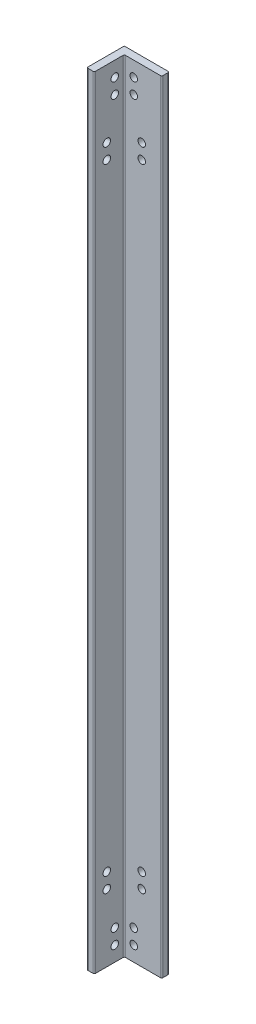
from build123d import *

# Parameters (mm, degrees)
SKETCH1_W           = 15
SKETCH1_H           = 313
SKETCH1_R           = 1.5
BOSS_EXTRUDE2_DEPTH = 3
SKETCH1_4_W         = 3
SKETCH1_4_H         = 313
BOSS_EXTRUDE3_DEPTH = 15
CUT_EXTRUDE1_REACH  = 296.576
SKETCH2_R           = 1.5
FILLET1_R           = 0.5


with BuildPart() as part:
    # Sketch1 → Boss-Extrude2 (new body)
    with BuildSketch(Plane.XY):
        with Locations((7.842857143, -137.142857143)):
            Rectangle(SKETCH1_W, SKETCH1_H)
        with Locations((4.142857143, -287.642857143)):
            Circle(SKETCH1_R, mode=Mode.SUBTRACT)
        with Locations((4.142857143, -281.642857143)):
            Circle(SKETCH1_R, mode=Mode.SUBTRACT)
        with Locations((7.342857143, -266.642857143)):
            Circle(SKETCH1_R, mode=Mode.SUBTRACT)
        with Locations((7.342857143, -260.642857143)):
            Circle(SKETCH1_R, mode=Mode.SUBTRACT)
        with Locations((4.142857143, 7.357142857)):
            Circle(SKETCH1_R, mode=Mode.SUBTRACT)
        with Locations((4.142857143, 13.357142857)):
            Circle(SKETCH1_R, mode=Mode.SUBTRACT)
        with Locations((7.342857143, -13.642857143)):
            Circle(SKETCH1_R, mode=Mode.SUBTRACT)
        with Locations((7.342857143, -7.642857143)):
            Circle(SKETCH1_R, mode=Mode.SUBTRACT)
    extrude(amount=BOSS_EXTRUDE2_DEPTH)

    # Sketch1_4 → Boss-Extrude3 (add)
    with BuildSketch(Plane.XY):
        with Locations((-1.157142857, -137.142857143)):
            Rectangle(SKETCH1_4_W, SKETCH1_4_H)
    extrude(amount=BOSS_EXTRUDE3_DEPTH)

    # Sketch2 → Cut-Extrude1 (cut, up to next)
    with BuildSketch(Plane.ZY.offset(2.657142857), mode=Mode.PRIVATE) as cut_extrude1_sk1:
        with Locations((6.8, 13.357142857)):
            Circle(SKETCH2_R)
    cut_extrude1_tool1 = extrude(cut_extrude1_sk1.sketch, amount=-CUT_EXTRUDE1_REACH, mode=Mode.PRIVATE) & part.part
    # Sketch2 → Cut-Extrude1 (cut, up to next)
    with BuildSketch(Plane.ZY.offset(2.657142857), mode=Mode.PRIVATE) as cut_extrude1_sk2:
        with Locations((6.8, -287.642857143)):
            Circle(SKETCH2_R)
    cut_extrude1_tool2 = extrude(cut_extrude1_sk2.sketch, amount=-CUT_EXTRUDE1_REACH, mode=Mode.PRIVATE) & part.part
    # Sketch2 → Cut-Extrude1 (cut, up to next)
    with BuildSketch(Plane.ZY.offset(2.657142857), mode=Mode.PRIVATE) as cut_extrude1_sk3:
        with Locations((6.8, -281.642857143)):
            Circle(SKETCH2_R)
    cut_extrude1_tool3 = extrude(cut_extrude1_sk3.sketch, amount=-CUT_EXTRUDE1_REACH, mode=Mode.PRIVATE) & part.part
    # Sketch2 → Cut-Extrude1 (cut, up to next)
    with BuildSketch(Plane.ZY.offset(2.657142857), mode=Mode.PRIVATE) as cut_extrude1_sk4:
        with Locations((6.8, 7.357142857)):
            Circle(SKETCH2_R)
    cut_extrude1_tool4 = extrude(cut_extrude1_sk4.sketch, amount=-CUT_EXTRUDE1_REACH, mode=Mode.PRIVATE) & part.part
    # Sketch2 → Cut-Extrude1 (cut, up to next)
    with BuildSketch(Plane.ZY.offset(2.657142857), mode=Mode.PRIVATE) as cut_extrude1_sk5:
        with Locations((10, -266.642857143)):
            Circle(SKETCH2_R)
    cut_extrude1_tool5 = extrude(cut_extrude1_sk5.sketch, amount=-CUT_EXTRUDE1_REACH, mode=Mode.PRIVATE) & part.part
    # Sketch2 → Cut-Extrude1 (cut, up to next)
    with BuildSketch(Plane.ZY.offset(2.657142857), mode=Mode.PRIVATE) as cut_extrude1_sk6:
        with Locations((10, -260.642857143)):
            Circle(SKETCH2_R)
    cut_extrude1_tool6 = extrude(cut_extrude1_sk6.sketch, amount=-CUT_EXTRUDE1_REACH, mode=Mode.PRIVATE) & part.part
    # Sketch2 → Cut-Extrude1 (cut, up to next)
    with BuildSketch(Plane.ZY.offset(2.657142857), mode=Mode.PRIVATE) as cut_extrude1_sk7:
        with Locations((10, -13.642857143)):
            Circle(SKETCH2_R)
    cut_extrude1_tool7 = extrude(cut_extrude1_sk7.sketch, amount=-CUT_EXTRUDE1_REACH, mode=Mode.PRIVATE) & part.part
    # Sketch2 → Cut-Extrude1 (cut, up to next)
    with BuildSketch(Plane.ZY.offset(2.657142857), mode=Mode.PRIVATE) as cut_extrude1_sk8:
        with Locations((10, -7.642857143)):
            Circle(SKETCH2_R)
    cut_extrude1_tool8 = extrude(cut_extrude1_sk8.sketch, amount=-CUT_EXTRUDE1_REACH, mode=Mode.PRIVATE) & part.part
    add(cut_extrude1_tool1.solids().sort_by_distance((-2.657143, 13.357143, 6.8))[0], mode=Mode.SUBTRACT)
    add(cut_extrude1_tool2.solids().sort_by_distance((-2.657143, -287.642857, 6.8))[0], mode=Mode.SUBTRACT)
    add(cut_extrude1_tool3.solids().sort_by_distance((-2.657143, -281.642857, 6.8))[0], mode=Mode.SUBTRACT)
    add(cut_extrude1_tool4.solids().sort_by_distance((-2.657143, 7.357143, 6.8))[0], mode=Mode.SUBTRACT)
    add(cut_extrude1_tool5.solids().sort_by_distance((-2.657143, -266.642857, 10))[0], mode=Mode.SUBTRACT)
    add(cut_extrude1_tool6.solids().sort_by_distance((-2.657143, -260.642857, 10))[0], mode=Mode.SUBTRACT)
    add(cut_extrude1_tool7.solids().sort_by_distance((-2.657143, -13.642857, 10))[0], mode=Mode.SUBTRACT)
    add(cut_extrude1_tool8.solids().sort_by_distance((-2.657143, -7.642857, 10))[0], mode=Mode.SUBTRACT)

    # Fillet1
    fillet1_edges = [part.edges().sort_by_distance(p)[0] for p in [
        (15.342857143, -137.142857143, 0),
        (15.342857143, -137.142857143, 3),
        (-2.657142857, -137.142857143, 15),
        (0.342857143, -137.142857143, 15),
        (0.342857143, -137.142857143, 3),
    ]]
    fillet(fillet1_edges, radius=FILLET1_R)


solid = part.part
